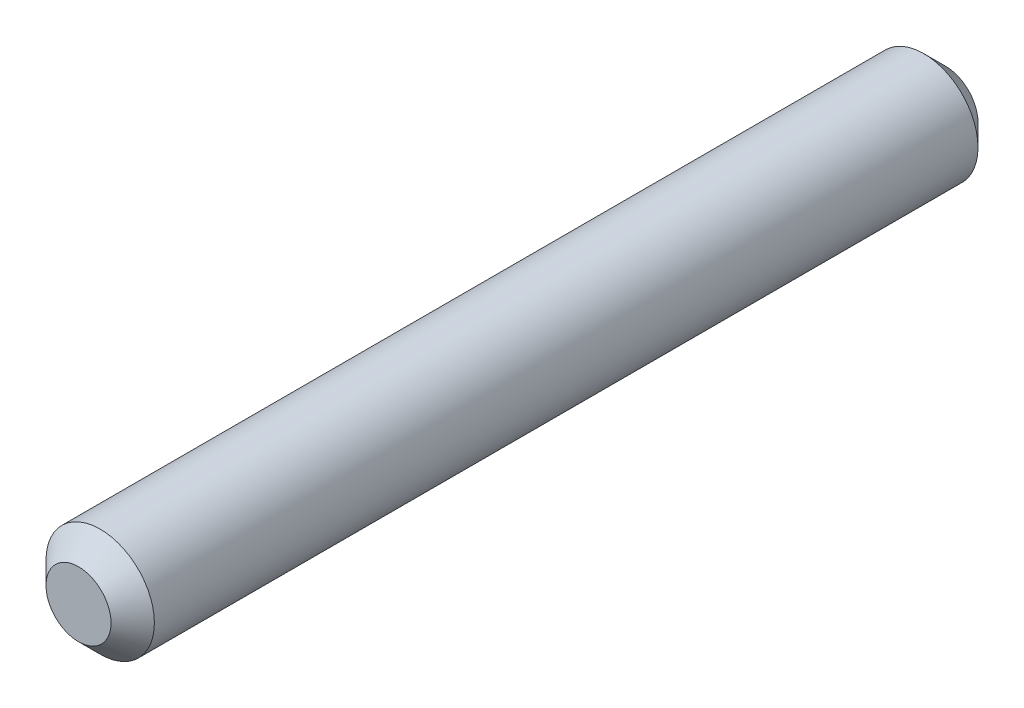
from build123d import *

# Parameters (mm, degrees)
SKETCH_1_R      = 2.5
EXTRUDE_1_DEPTH = 40
CHAMFER_1_SIZE  = 1
CHAMFER_2_SIZE  = 1


with BuildPart() as part:
    # Эскиз1 → Бобышка-Вытянуть1 (new body)
    with BuildSketch(Plane.XY):
        Circle(SKETCH_1_R)
    extrude(amount=EXTRUDE_1_DEPTH)

    # Фаска1
    chamfer_1_edges = [part.edges().sort_by_distance(p)[0] for p in [
        (-2.5, 0, 40),
    ]]
    chamfer(chamfer_1_edges, length=CHAMFER_1_SIZE)

    # Фаска2
    chamfer_2_edges = [part.edges().sort_by_distance(p)[0] for p in [
        (-2.5, 0, 0),
    ]]
    chamfer(chamfer_2_edges, length=CHAMFER_2_SIZE)


solid = part.part
